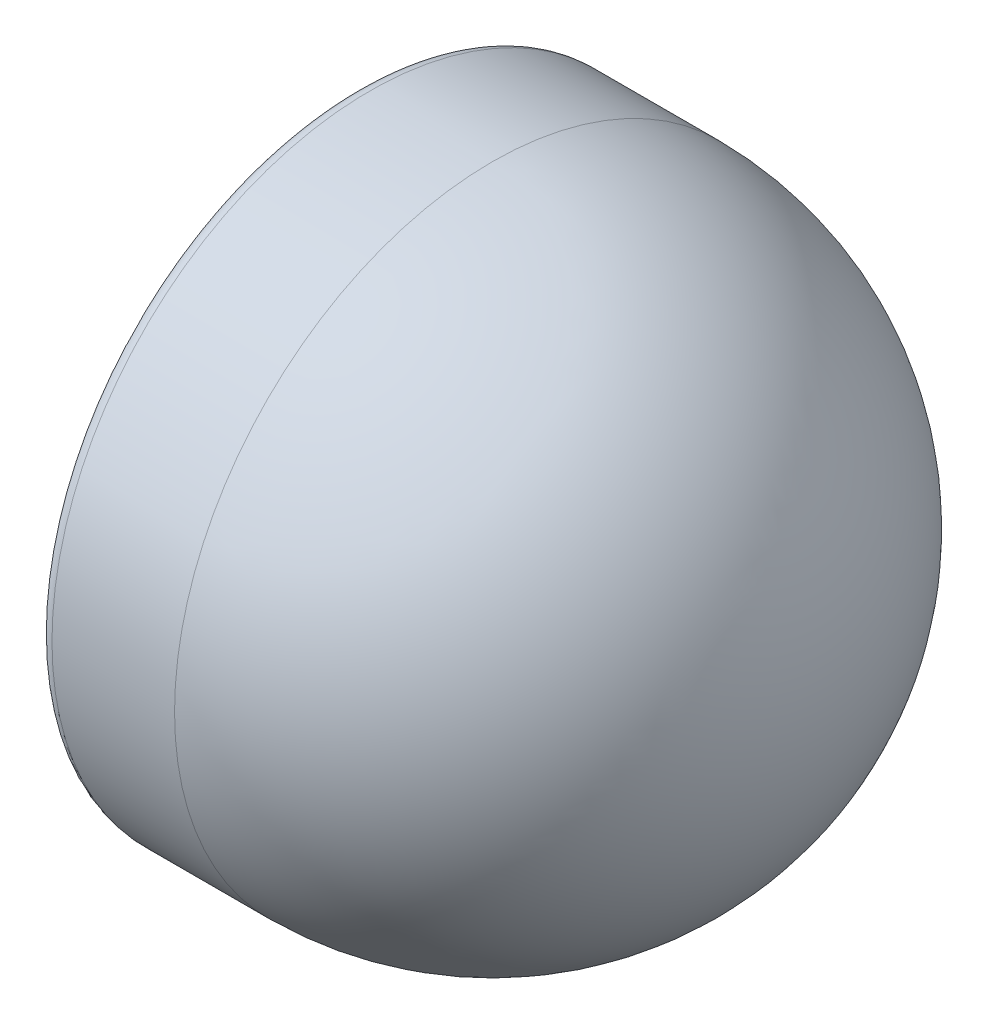
from build123d import *


with BuildPart() as part:
    # Sketch1 → Revolve1 (revolve)
    with BuildSketch(Plane.XY):
        with BuildLine():
            Line((-70, 70), (-97, 70))
            ThreePointArc((-97, 70), (-99.121320344, 69.121320344), (-100, 67))
            Line((-100, 67), (-100, 61.5))
            ThreePointArc((-100, 61.5), (-99.560660172, 60.439339828), (-98.5, 60))
            Line((-98.5, 60), (-96.621320344, 60))
            ThreePointArc((-96.621320344, 60), (-96.047295195, 60.114180701), (-95.560660172, 60.439339828))
            Line((-95.560660172, 60.439339828), (-92, 64))
            Line((-92, 64), (-92, 64.707106781))
            Line((-92, 64.707106781), (-92.707106781, 64.707106781))
            Line((-92.707106781, 64.707106781), (-96.267766953, 61.146446609))
            ThreePointArc((-96.267766953, 61.146446609), (-96.429978627, 61.038060234), (-96.621320344, 61))
            Line((-96.621320344, 61), (-98.5, 61))
            ThreePointArc((-98.5, 61), (-98.853553391, 61.146446609), (-99, 61.5))
            Line((-99, 61.5), (-99, 67))
            ThreePointArc((-99, 67), (-98.414213562, 68.414213562), (-97, 69))
            Line((-97, 69), (-70, 69))
            ThreePointArc((-70, 69), (-21.209632098, 48.790367902), (-1, 0))
            Line((-1, 0), (0, 0))
            ThreePointArc((0, 0), (-20.502525317, 49.497474683), (-70, 70))
        make_face()
    revolve(axis=Axis((-70, 0, 0), (1, 0, 0)))


solid = part.part
